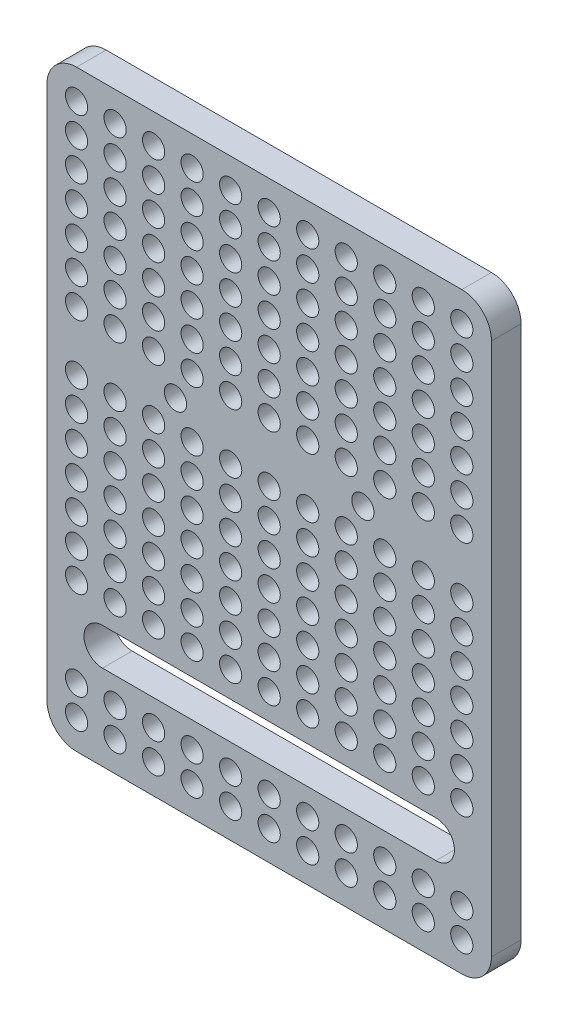
from build123d import *

# Parameters (mm, degrees)
EXTRUDE_1_DEPTH     = 4
CUT_EXTRUDE_1_DEPTH = 4
SKETCH_3_R          = 1.5
CUT_EXTRUDE_2_DEPTH = 4


with BuildPart() as part:
    # Эскиз1 → Бобышка-Вытянуть1 (new body)
    with BuildSketch(Plane.XY):
        with BuildLine():
            Line((4, 0), (56, 0))
            ThreePointArc((56, 0), (58.828427125, 1.171572875), (60, 4))
            Line((60, 4), (60, 76))
            ThreePointArc((60, 76), (58.828427125, 78.828427125), (56, 80))
            Line((56, 80), (4, 80))
            ThreePointArc((4, 80), (1.171572875, 78.828427125), (0, 76))
            Line((0, 76), (0, 4))
            ThreePointArc((0, 4), (1.171572875, 1.171572875), (4, 0))
        make_face()
    extrude(amount=EXTRUDE_1_DEPTH)

    # Эскиз2 → Вырез-Вытянуть1 (cut)
    with BuildSketch(Plane.XY.offset(4)):
        with BuildLine():
            Line((7.5, 16.5), (52.5, 16.5))
            ThreePointArc((52.5, 16.5), (55, 14), (52.5, 11.5))
            Line((52.5, 11.5), (7.5, 11.5))
            ThreePointArc((7.5, 11.5), (5, 14), (7.5, 16.5))
        make_face()
    extrude(amount=-CUT_EXTRUDE_1_DEPTH, mode=Mode.SUBTRACT)

    # Эскиз3 → Вырез-Вытянуть2 (cut)
    with BuildSketch(Plane.XY.offset(4)):
        with Locations((4, 76)):
            Circle(SKETCH_3_R)
        with Locations((9.2, 76)):
            Circle(SKETCH_3_R)
        with Locations((14.4, 76)):
            Circle(SKETCH_3_R)
        with Locations((19.6, 76)):
            Circle(SKETCH_3_R)
        with Locations((24.8, 76)):
            Circle(SKETCH_3_R)
        with Locations((30, 76)):
            Circle(SKETCH_3_R)
        with Locations((35.2, 76)):
            Circle(SKETCH_3_R)
        with Locations((40.4, 76)):
            Circle(SKETCH_3_R)
        with Locations((45.6, 76)):
            Circle(SKETCH_3_R)
        with Locations((50.8, 76)):
            Circle(SKETCH_3_R)
        with Locations((56, 76)):
            Circle(SKETCH_3_R)
        with Locations((4, 72)):
            Circle(SKETCH_3_R)
        with Locations((9.2, 72)):
            Circle(SKETCH_3_R)
        with Locations((14.4, 72)):
            Circle(SKETCH_3_R)
        with Locations((19.6, 72)):
            Circle(SKETCH_3_R)
        with Locations((24.8, 72)):
            Circle(SKETCH_3_R)
        with Locations((30, 72)):
            Circle(SKETCH_3_R)
        with Locations((35.2, 72)):
            Circle(SKETCH_3_R)
        with Locations((40.4, 72)):
            Circle(SKETCH_3_R)
        with Locations((45.6, 72)):
            Circle(SKETCH_3_R)
        with Locations((50.8, 72)):
            Circle(SKETCH_3_R)
        with Locations((56, 72)):
            Circle(SKETCH_3_R)
        with Locations((4, 68)):
            Circle(SKETCH_3_R)
        with Locations((9.2, 68)):
            Circle(SKETCH_3_R)
        with Locations((14.4, 68)):
            Circle(SKETCH_3_R)
        with Locations((19.6, 68)):
            Circle(SKETCH_3_R)
        with Locations((24.8, 68)):
            Circle(SKETCH_3_R)
        with Locations((30, 68)):
            Circle(SKETCH_3_R)
        with Locations((35.2, 68)):
            Circle(SKETCH_3_R)
        with Locations((40.4, 68)):
            Circle(SKETCH_3_R)
        with Locations((45.6, 68)):
            Circle(SKETCH_3_R)
        with Locations((50.8, 68)):
            Circle(SKETCH_3_R)
        with Locations((56, 68)):
            Circle(SKETCH_3_R)
        with Locations((4, 64)):
            Circle(SKETCH_3_R)
        with Locations((9.2, 64)):
            Circle(SKETCH_3_R)
        with Locations((14.4, 64)):
            Circle(SKETCH_3_R)
        with Locations((19.6, 64)):
            Circle(SKETCH_3_R)
        with Locations((24.8, 64)):
            Circle(SKETCH_3_R)
        with Locations((30, 64)):
            Circle(SKETCH_3_R)
        with Locations((35.2, 64)):
            Circle(SKETCH_3_R)
        with Locations((40.4, 64)):
            Circle(SKETCH_3_R)
        with Locations((45.6, 64)):
            Circle(SKETCH_3_R)
        with Locations((50.8, 64)):
            Circle(SKETCH_3_R)
        with Locations((56, 64)):
            Circle(SKETCH_3_R)
        with Locations((4, 60)):
            Circle(SKETCH_3_R)
        with Locations((9.2, 60)):
            Circle(SKETCH_3_R)
        with Locations((14.4, 60)):
            Circle(SKETCH_3_R)
        with Locations((19.6, 60)):
            Circle(SKETCH_3_R)
        with Locations((24.8, 60)):
            Circle(SKETCH_3_R)
        with Locations((30, 60)):
            Circle(SKETCH_3_R)
        with Locations((35.2, 60)):
            Circle(SKETCH_3_R)
        with Locations((40.4, 60)):
            Circle(SKETCH_3_R)
        with Locations((45.6, 60)):
            Circle(SKETCH_3_R)
        with Locations((50.8, 60)):
            Circle(SKETCH_3_R)
        with Locations((56, 60)):
            Circle(SKETCH_3_R)
        with Locations((4, 56)):
            Circle(SKETCH_3_R)
        with Locations((9.2, 56)):
            Circle(SKETCH_3_R)
        with Locations((14.4, 56)):
            Circle(SKETCH_3_R)
        with Locations((19.6, 56)):
            Circle(SKETCH_3_R)
        with Locations((24.8, 56)):
            Circle(SKETCH_3_R)
        with Locations((30, 56)):
            Circle(SKETCH_3_R)
        with Locations((35.2, 56)):
            Circle(SKETCH_3_R)
        with Locations((40.4, 56)):
            Circle(SKETCH_3_R)
        with Locations((45.6, 56)):
            Circle(SKETCH_3_R)
        with Locations((50.8, 56)):
            Circle(SKETCH_3_R)
        with Locations((56, 56)):
            Circle(SKETCH_3_R)
        with Locations((4, 52)):
            Circle(SKETCH_3_R)
        with Locations((9.2, 52)):
            Circle(SKETCH_3_R)
        with Locations((14.4, 52)):
            Circle(SKETCH_3_R)
        with Locations((19.6, 52)):
            Circle(SKETCH_3_R)
        with Locations((24.8, 52)):
            Circle(SKETCH_3_R)
        with Locations((30, 52)):
            Circle(SKETCH_3_R)
        with Locations((35.2, 52)):
            Circle(SKETCH_3_R)
        with Locations((40.4, 52)):
            Circle(SKETCH_3_R)
        with Locations((45.6, 52)):
            Circle(SKETCH_3_R)
        with Locations((50.8, 52)):
            Circle(SKETCH_3_R)
        with Locations((56, 52)):
            Circle(SKETCH_3_R)
        with Locations((4, 44)):
            Circle(SKETCH_3_R)
        with Locations((9.2, 44)):
            Circle(SKETCH_3_R)
        with Locations((14.4, 44)):
            Circle(SKETCH_3_R)
        with Locations((19.6, 44)):
            Circle(SKETCH_3_R)
        with Locations((24.8, 44)):
            Circle(SKETCH_3_R)
        with Locations((30, 44)):
            Circle(SKETCH_3_R)
        with Locations((35.2, 44)):
            Circle(SKETCH_3_R)
        with Locations((40.4, 44)):
            Circle(SKETCH_3_R)
        with Locations((45.6, 44)):
            Circle(SKETCH_3_R)
        with Locations((50.8, 44)):
            Circle(SKETCH_3_R)
        with Locations((56, 44)):
            Circle(SKETCH_3_R)
        with Locations((4, 40)):
            Circle(SKETCH_3_R)
        with Locations((9.2, 40)):
            Circle(SKETCH_3_R)
        with Locations((14.4, 40)):
            Circle(SKETCH_3_R)
        with Locations((19.6, 40)):
            Circle(SKETCH_3_R)
        with Locations((24.8, 40)):
            Circle(SKETCH_3_R)
        with Locations((30, 40)):
            Circle(SKETCH_3_R)
        with Locations((35.2, 40)):
            Circle(SKETCH_3_R)
        with Locations((40.4, 40)):
            Circle(SKETCH_3_R)
        with Locations((45.6, 40)):
            Circle(SKETCH_3_R)
        with Locations((50.8, 40)):
            Circle(SKETCH_3_R)
        with Locations((56, 40)):
            Circle(SKETCH_3_R)
        with Locations((4, 36)):
            Circle(SKETCH_3_R)
        with Locations((9.2, 36)):
            Circle(SKETCH_3_R)
        with Locations((14.4, 36)):
            Circle(SKETCH_3_R)
        with Locations((19.6, 36)):
            Circle(SKETCH_3_R)
        with Locations((24.8, 36)):
            Circle(SKETCH_3_R)
        with Locations((30, 36)):
            Circle(SKETCH_3_R)
        with Locations((35.2, 36)):
            Circle(SKETCH_3_R)
        with Locations((40.4, 36)):
            Circle(SKETCH_3_R)
        with Locations((45.6, 36)):
            Circle(SKETCH_3_R)
        with Locations((50.8, 36)):
            Circle(SKETCH_3_R)
        with Locations((56, 36)):
            Circle(SKETCH_3_R)
        with Locations((4, 32)):
            Circle(SKETCH_3_R)
        with Locations((9.2, 32)):
            Circle(SKETCH_3_R)
        with Locations((14.4, 32)):
            Circle(SKETCH_3_R)
        with Locations((19.6, 32)):
            Circle(SKETCH_3_R)
        with Locations((24.8, 32)):
            Circle(SKETCH_3_R)
        with Locations((30, 32)):
            Circle(SKETCH_3_R)
        with Locations((35.2, 32)):
            Circle(SKETCH_3_R)
        with Locations((40.4, 32)):
            Circle(SKETCH_3_R)
        with Locations((45.6, 32)):
            Circle(SKETCH_3_R)
        with Locations((50.8, 32)):
            Circle(SKETCH_3_R)
        with Locations((56, 32)):
            Circle(SKETCH_3_R)
        with Locations((4, 28)):
            Circle(SKETCH_3_R)
        with Locations((9.2, 28)):
            Circle(SKETCH_3_R)
        with Locations((14.4, 28)):
            Circle(SKETCH_3_R)
        with Locations((19.6, 28)):
            Circle(SKETCH_3_R)
        with Locations((24.8, 28)):
            Circle(SKETCH_3_R)
        with Locations((30, 28)):
            Circle(SKETCH_3_R)
        with Locations((35.2, 28)):
            Circle(SKETCH_3_R)
        with Locations((40.4, 28)):
            Circle(SKETCH_3_R)
        with Locations((45.6, 28)):
            Circle(SKETCH_3_R)
        with Locations((50.8, 28)):
            Circle(SKETCH_3_R)
        with Locations((56, 28)):
            Circle(SKETCH_3_R)
        with Locations((4, 24)):
            Circle(SKETCH_3_R)
        with Locations((9.2, 24)):
            Circle(SKETCH_3_R)
        with Locations((14.4, 24)):
            Circle(SKETCH_3_R)
        with Locations((19.6, 24)):
            Circle(SKETCH_3_R)
        with Locations((24.8, 24)):
            Circle(SKETCH_3_R)
        with Locations((30, 24)):
            Circle(SKETCH_3_R)
        with Locations((35.2, 24)):
            Circle(SKETCH_3_R)
        with Locations((40.4, 24)):
            Circle(SKETCH_3_R)
        with Locations((45.6, 24)):
            Circle(SKETCH_3_R)
        with Locations((50.8, 24)):
            Circle(SKETCH_3_R)
        with Locations((56, 24)):
            Circle(SKETCH_3_R)
        with Locations((4, 20)):
            Circle(SKETCH_3_R)
        with Locations((9.2, 20)):
            Circle(SKETCH_3_R)
        with Locations((14.4, 20)):
            Circle(SKETCH_3_R)
        with Locations((19.6, 20)):
            Circle(SKETCH_3_R)
        with Locations((24.8, 20)):
            Circle(SKETCH_3_R)
        with Locations((30, 20)):
            Circle(SKETCH_3_R)
        with Locations((35.2, 20)):
            Circle(SKETCH_3_R)
        with Locations((40.4, 20)):
            Circle(SKETCH_3_R)
        with Locations((45.6, 20)):
            Circle(SKETCH_3_R)
        with Locations((50.8, 20)):
            Circle(SKETCH_3_R)
        with Locations((56, 20)):
            Circle(SKETCH_3_R)
        with Locations((4, 8)):
            Circle(SKETCH_3_R)
        with Locations((9.2, 8)):
            Circle(SKETCH_3_R)
        with Locations((14.4, 8)):
            Circle(SKETCH_3_R)
        with Locations((19.6, 8)):
            Circle(SKETCH_3_R)
        with Locations((24.8, 8)):
            Circle(SKETCH_3_R)
        with Locations((30, 8)):
            Circle(SKETCH_3_R)
        with Locations((35.2, 8)):
            Circle(SKETCH_3_R)
        with Locations((40.4, 8)):
            Circle(SKETCH_3_R)
        with Locations((45.6, 8)):
            Circle(SKETCH_3_R)
        with Locations((50.8, 8)):
            Circle(SKETCH_3_R)
        with Locations((56, 8)):
            Circle(SKETCH_3_R)
        with Locations((4, 4)):
            Circle(SKETCH_3_R)
        with Locations((9.2, 4)):
            Circle(SKETCH_3_R)
        with Locations((14.4, 4)):
            Circle(SKETCH_3_R)
        with Locations((19.6, 4)):
            Circle(SKETCH_3_R)
        with Locations((24.8, 4)):
            Circle(SKETCH_3_R)
        with Locations((30, 4)):
            Circle(SKETCH_3_R)
        with Locations((35.2, 4)):
            Circle(SKETCH_3_R)
        with Locations((40.4, 4)):
            Circle(SKETCH_3_R)
        with Locations((45.6, 4)):
            Circle(SKETCH_3_R)
        with Locations((50.8, 4)):
            Circle(SKETCH_3_R)
        with Locations((56, 4)):
            Circle(SKETCH_3_R)
        with Locations((17.35, 47.998495315)):
            Circle(SKETCH_3_R)
        with Locations((42.65, 47.998495315)):
            Circle(SKETCH_3_R)
    extrude(amount=-CUT_EXTRUDE_2_DEPTH, mode=Mode.SUBTRACT)


solid = part.part
